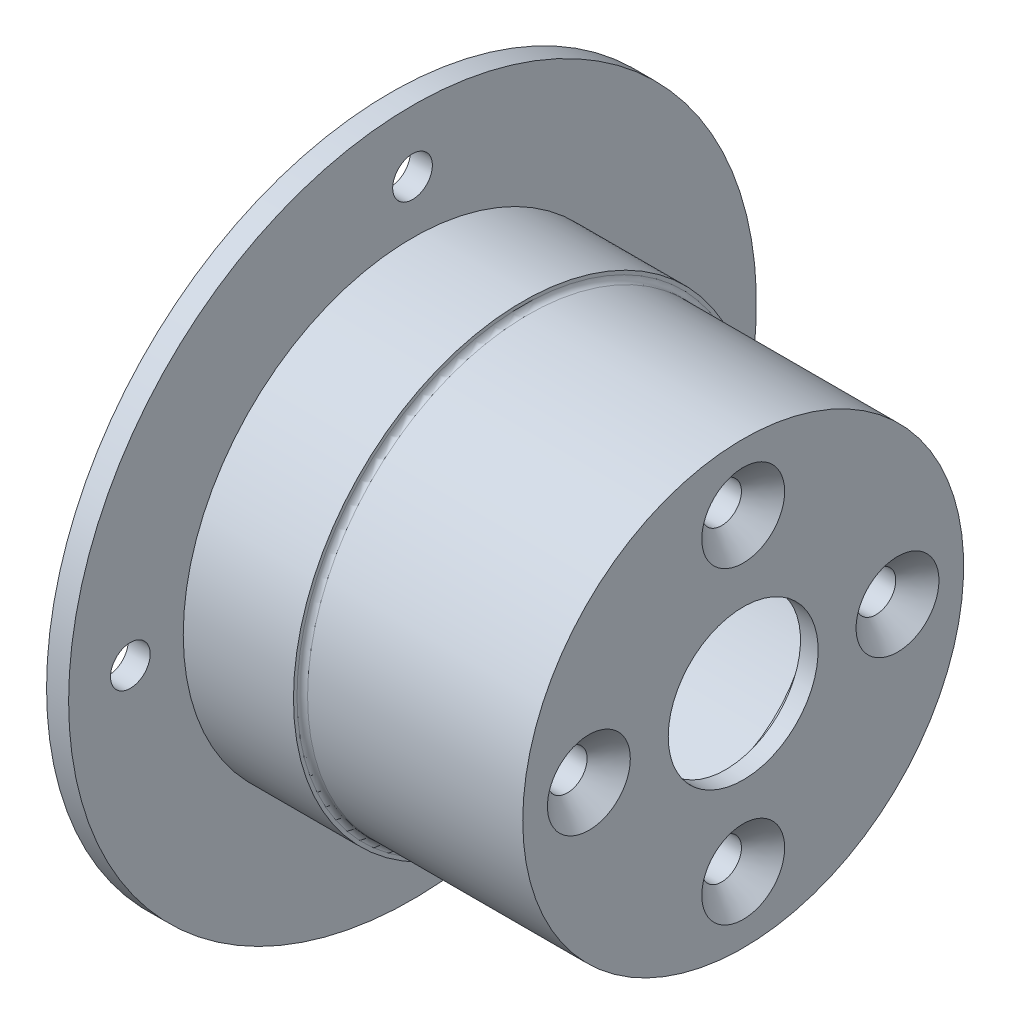
from build123d import *

# Parameters (mm, degrees)
CSK_FOR_M4_FLAT_HEAD_MACHINE_SCREW1_D           = 4.5
CSK_FOR_M4_FLAT_HEAD_MACHINE_SCREW1_DEPTH       = 5
CSK_FOR_M4_FLAT_HEAD_MACHINE_SCREW1_CSINK_D     = 9.4
CSK_FOR_M4_FLAT_HEAD_MACHINE_SCREW1_CSINK_ANGLE = 90
FILLET1_R                                       = 0.6
M4_CLEARANCE_HOLE1_D                            = 4.5
M4_CLEARANCE_HOLE1_DEPTH                        = 2.5


with BuildPart() as part:
    # Sketch2 → Revolve1 (revolve)
    with BuildSketch(Plane.XY):
        Polygon((0, 21), (35, 21), (35, 12.5), (38, 12.5), (38, 8.5), (40, 8.5), (40, 25), (15, 25), (15, 26), (2.5, 26), (2.5, 39), (0, 39), (0, 26), align=None)
    revolve(axis=Axis((-64.103352454, 0, 0), (1, 0, 0)))

    # CSK for M4 Flat Head Machine Screw1
    with Locations(Plane(origin=(40, 0, 0), x_dir=(0, 0, -1), z_dir=(1, 0, 0))):
        with Locations((0, 17.5), (17.5, 0), (0, -17.5), (-17.5, 0)):
            CounterSinkHole(CSK_FOR_M4_FLAT_HEAD_MACHINE_SCREW1_D / 2, CSK_FOR_M4_FLAT_HEAD_MACHINE_SCREW1_CSINK_D / 2, depth=CSK_FOR_M4_FLAT_HEAD_MACHINE_SCREW1_DEPTH, counter_sink_angle=CSK_FOR_M4_FLAT_HEAD_MACHINE_SCREW1_CSINK_ANGLE)

    # Fillet1
    fillet1_edges = [part.edges().sort_by_distance(p)[0] for p in [
        (15, -25, 0),
    ]]
    fillet(fillet1_edges, radius=FILLET1_R)

    # M4 Clearance Hole1
    with Locations(Plane.ZY):
        with Locations((0, 32), (0, -32), (32, 0), (-32, 0)):
            Hole(M4_CLEARANCE_HOLE1_D / 2, depth=M4_CLEARANCE_HOLE1_DEPTH)


solid = part.part
